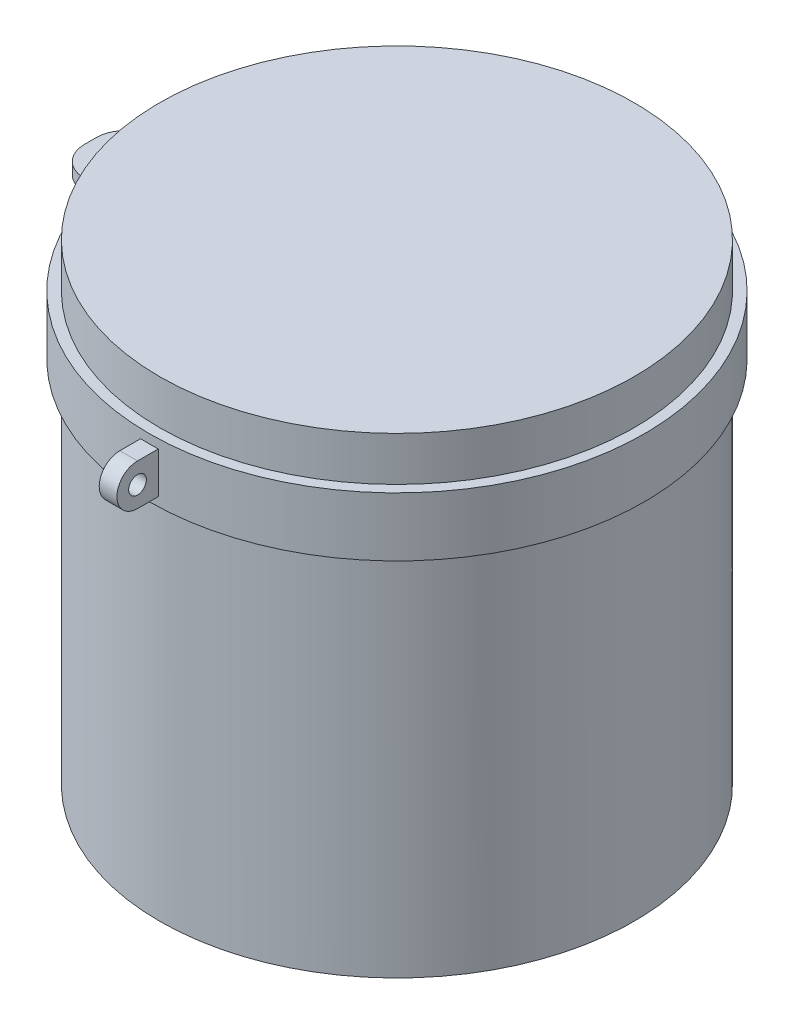
from build123d import *

# Parameters (mm, degrees)
SKETCH_2_W      = 40
SKETCH_2_H      = 200
SKETCH_3_R      = 30
EXTRUDE_1_DEPTH = 30
EXTRUDE_2_DEPTH = 20
SKETCH_6_R      = 805
SKETCH_5_R      = 805


with BuildPart() as part:
    # Эскиз2 → Повернуть2 (revolve)
    with BuildSketch(Plane.XY):
        with Locations((-820, 1350)):
            Rectangle(SKETCH_2_W, SKETCH_2_H)
    revolve(axis=Axis((0, 1662.873032591, 0), (0, -1, 0)))

    # Эскиз3 → Бобышка-Вытянуть1 (add, symmetric)
    with BuildSketch(Plane(origin=(0, 0, 0), x_dir=(0, 0, -1), z_dir=(1, 0, 0))):
        with BuildLine():
            Line((-800, 1280), (-910, 1280))
            ThreePointArc((-910, 1280), (-980, 1350), (-910, 1420))
            Line((-910, 1420), (-800, 1420))
            Line((-800, 1420), (-800, 1280))
        make_face()
        with Locations((-910, 1350)):
            Circle(SKETCH_3_R, mode=Mode.SUBTRACT)
    extrude(amount=EXTRUDE_1_DEPTH, both=True)

    # Эскиз4 → Бобышка-Вытянуть2 (add, symmetric)
    with BuildSketch(Plane(origin=(0, 1350, 0), x_dir=(1, 0, 0), z_dir=(0, 1, 0))):
        with BuildLine():
            Line((-831.384387633, 120), (-940, 120))
            ThreePointArc((-940, 120), (-1010.710678119, 90.710678119), (-1040, 20))
            Line((-1040, 20), (-1040, -20))
            ThreePointArc((-1040, -20), (-1010.710678119, -90.710678119), (-940, -120))
            Line((-940, -120), (-831.384387633, -120))
            ThreePointArc((-831.384387633, -120), (-840, 0), (-831.384387633, 120))
        make_face()
        with BuildLine():
            Line((-895, -25), (-895, 25))
            ThreePointArc((-895, 25), (-906.715728753, 53.284271247), (-935, 65))
            Line((-935, 65), (-945, 65))
            ThreePointArc((-945, 65), (-973.284271247, 53.284271247), (-985, 25))
            Line((-985, 25), (-985, -25))
            ThreePointArc((-985, -25), (-973.284271247, -53.284271247), (-945, -65))
            Line((-945, -65), (-935, -65))
            ThreePointArc((-935, -65), (-906.715728753, -53.284271247), (-895, -25))
        make_face(mode=Mode.SUBTRACT)
    extrude(amount=EXTRUDE_2_DEPTH, both=True)

    # Эскиз6 → По сечениям2 section 0
    with BuildSketch(Plane(origin=(0, 1600, 0), x_dir=(1, 0, 0), z_dir=(0, 1, 0))):
        Circle(SKETCH_6_R)
    # Эскиз5 → По сечениям2 section 1
    with BuildSketch(Plane(origin=(0, 0, 0), x_dir=(1, 0, 0), z_dir=(0, 1, 0))):
        Circle(SKETCH_5_R)
    loft()


solid = part.part
